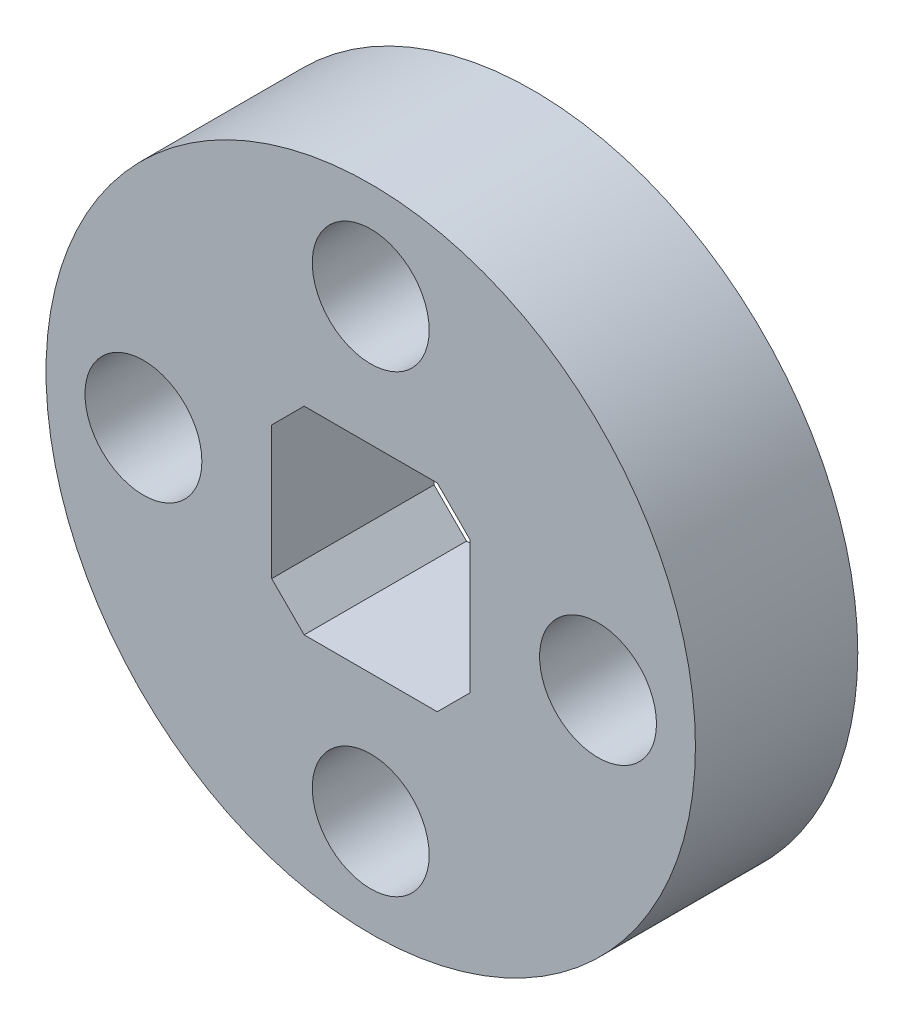
from build123d import *

# Parameters (mm, degrees)
ESQUISSE1_R                  = 10
ESQUISSE1_W                  = 6.1
ESQUISSE1_H                  = 6.1
BOSS_EXTRU_1_DEPTH           = 5
ESQUISSE2_R                  = 1.8
ENL_V_MAT_EXTRU_1_DEPTH      = 1
ENL_V_MAT_EXTRU_1_DEPTH_BACK = 6
CHANFREIN1_SIZE              = 1


with BuildPart() as part:
    # Esquisse1 → Boss.-Extru.1 (new body)
    with BuildSketch(Plane.XY):
        Circle(ESQUISSE1_R)
        Rectangle(ESQUISSE1_W, ESQUISSE1_H, mode=Mode.SUBTRACT)
    extrude(amount=BOSS_EXTRU_1_DEPTH)

    # Esquisse2 → Enlèv. mat.-Extru.1 (cut, two sides)
    with BuildSketch(Plane.XY.offset(5)) as enl_v_mat_extru_1_sk:
        with Locations((0, 7)):
            Circle(ESQUISSE2_R)
        with Locations((7, 0)):
            Circle(ESQUISSE2_R)
        with Locations((0, -7)):
            Circle(ESQUISSE2_R)
        with Locations((-7, 0)):
            Circle(ESQUISSE2_R)
    extrude(amount=ENL_V_MAT_EXTRU_1_DEPTH, mode=Mode.SUBTRACT)
    extrude(enl_v_mat_extru_1_sk.sketch, amount=-ENL_V_MAT_EXTRU_1_DEPTH_BACK, mode=Mode.SUBTRACT)

    # Chanfrein1
    chanfrein1_edges = [part.edges().sort_by_distance(p)[0] for p in [
        (3.05, -3.05, 2.5),
        (3.05, 3.05, 2.5),
        (-3.05, 3.05, 2.5),
        (-3.05, -3.05, 2.5),
    ]]
    chamfer(chanfrein1_edges, length=CHANFREIN1_SIZE)


solid = part.part
